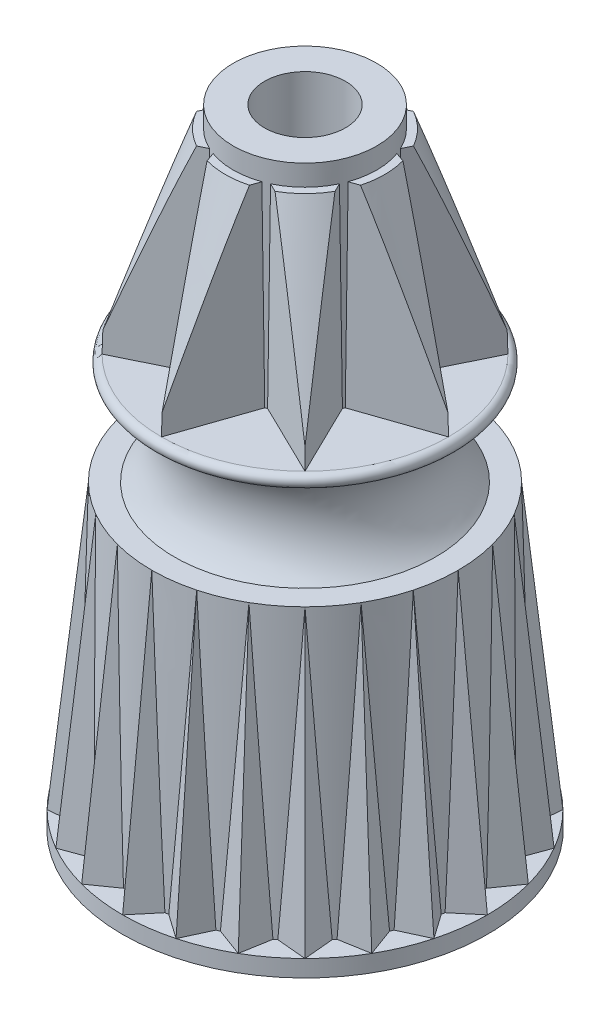
from build123d import *
from build123d.topology import SkipClean

# Parameters (mm, degrees)
SKETCH1_R           = 8.89
BOSS_EXTRUDE1_DEPTH = 0.8128
BOSS_EXTRUDE1_TAPER = 1
SKETCH2_R           = 7.4549
SKETCH3_R           = 7.8105
CIRPATTERN1_COUNT   = 24
SKETCH8_R           = 3.4925
BOSS_EXTRUDE2_DEPTH = 10.5156
SKETCH9_R           = 1.9685
CUT_EXTRUDE1_DEPTH  = 31.5308001
BOSS_EXTRUDE3_DEPTH = 9.4996
BOSS_EXTRUDE3_TAPER = 0.5
CIRPATTERN2_COUNT   = 8
FILLET1_R           = 0.762
RIB1_REACH          = 30.753
SKETCH13_WALLS_W    = 1.016
SKETCH13_WALLS_H    = 63.549878555
RIB1_DRAFT_ANGLE    = 1
FILLET2_R           = 0.508


with BuildPart() as part:
    # Sketch1 → Boss-Extrude1 (new body)
    with BuildSketch(Plane(origin=(0, 0, 0), x_dir=(1, 0, 0), z_dir=(0, 1, 0))):
        Circle(SKETCH1_R)
    extrude(amount=BOSS_EXTRUDE1_DEPTH, taper=BOSS_EXTRUDE1_TAPER)

    # Sketch2 → Loft1 section 0
    with BuildSketch(Plane(origin=(0, 14.6304, 0), x_dir=(1, 0, 0), z_dir=(0, 1, 0))):
        Circle(SKETCH2_R)
    # Sketch3 → Loft1 section 1
    with BuildSketch(Plane(origin=(0, 0.8128, 0), x_dir=(1, 0, 0), z_dir=(0, 1, 0))):
        Circle(SKETCH3_R)
    loft()

    # Sweep1: sweep along a path in Sketch4
    with SkipClean():  # keep this step's faces unmerged: merging them makes the solid invalid here
        with BuildLine(Plane(origin=(0, 0, 0), x_dir=(0, 0, -1), z_dir=(1, 0, 0))) as sweep1_path:
            Line((-8.875812523, 0.8128), (-7.4549, 14.6304))
        # Sketch5 → Sweep1 (sweep)
        with BuildSketch(Plane(origin=(0, 0.8128, 8.875812523), x_dir=(1, 0, 0), z_dir=(0, 0.994754201, -0.102294082))):
            Polygon((0, 0), (1.278787838, 1.524), (-1.278787838, 1.524), align=None)
        sweep1 = sweep(path=sweep1_path.line)

    # CirPattern1: Sweep1 ×24 about axis
    cirpattern1_axis = Axis((0, 0, 0), (0, 1, 0))
    for i in range(1, CIRPATTERN1_COUNT):
        add(sweep1.rotate(cirpattern1_axis, i * 360 / CIRPATTERN1_COUNT))

    # Sketch7 → Revolve1 (revolve)
    with BuildSketch(Plane(origin=(0, 0, 0), x_dir=(0, 0, -1), z_dir=(1, 0, 0))):
        with BuildLine():
            Line((0, 20.0152), (6.985, 20.0152))
            ThreePointArc((6.985, 20.0152), (7.3025, 19.6977), (6.985, 19.3802))
            Line((6.985, 19.3802), (6.35, 19.3802))
            ThreePointArc((6.35, 19.3802), (5.3467, 17.0053), (6.35, 14.6304))
            Line((6.35, 14.6304), (0, 14.6304))
            Line((0, 14.6304), (0, 20.0152))
        make_face()
    revolve(axis=Axis((0, 14.6304, 0), (0, 1, 0)))

    # Sketch8 → Boss-Extrude2 (add)
    with BuildSketch(Plane(origin=(0, 20.0152, 0), x_dir=(1, 0, 0), z_dir=(0, 1, 0))):
        with Locations(Location((0, 0, 0), (0, 0, 270))):  # turned: the seam where the file's is
            Circle(SKETCH8_R)
    extrude(amount=BOSS_EXTRUDE2_DEPTH)

    # Sketch9 → Cut-Extrude1 (cut, through all)
    with BuildSketch(Plane(origin=(0, 30.5308, 0), x_dir=(1, 0, 0), z_dir=(0, 1, 0))):
        with Locations(Location((0, 0, 0), (0, 0, 270))):  # turned: the seam where the file's is
            Circle(SKETCH9_R)
    extrude(amount=-CUT_EXTRUDE1_DEPTH, mode=Mode.SUBTRACT)

    # Sketch10 → Boss-Extrude3 (add)
    with BuildSketch(Plane(origin=(0, 20.0152, 0), x_dir=(1, 0, 0), z_dir=(0, 1, 0))):
        Polygon((0, -6.985), (1.56635116, -2.435985924), (-1.56635116, -2.435985924), align=None)
    boss_extrude3 = extrude(amount=BOSS_EXTRUDE3_DEPTH, taper=BOSS_EXTRUDE3_TAPER)

    # CirPattern2: Boss-Extrude3 ×8 about axis
    cirpattern2_axis = Axis((0, 0, 0), (0, 1, 0))
    for i in range(1, CIRPATTERN2_COUNT):
        add(boss_extrude3.rotate(cirpattern2_axis, i * 360 / CIRPATTERN2_COUNT))

    # Sketch11 → Cut-Revolve1 (revolve, cut)
    with BuildSketch(Plane(origin=(0, 0, 0), x_dir=(0, 0, -1), z_dir=(1, 0, 0)), mode=Mode.PRIVATE) as cut_revolve1_sk:
        Polygon((6.957775857, 21.030835193), (7.465775857, 21.030835193), (7.465775857, 30.5308), (3.4925, 30.5308), (3.4925, 29.5148), (3.8735, 29.5148), align=None)
    revolve(cut_revolve1_sk.sketch.rotate(Axis((0, 70.939881733, 0), (0, -1, 0)), 19.858501922), axis=Axis((0, 70.939881733, 0), (0, -1, 0)), mode=Mode.SUBTRACT)  # turned: the seam where the file's is

    # Sketch12 → Cut-Revolve2 (revolve, cut)
    with BuildSketch(Plane(origin=(0, 0, 0), x_dir=(0, 0, -1), z_dir=(1, 0, 0))):
        with BuildLine():
            Line((2.921, 0), (3.194108928, 15.6464))
            Line((3.194108928, 15.6464), (4.549542973, 15.6464))
            ThreePointArc((4.549542973, 15.6464), (4.990447661, 14.708323353), (5.641733851, 13.901966707))
            Line((5.641733851, 13.901966707), (5.889715871, 13.901966707))
            Line((5.889715871, 13.901966707), (6.270518716, 2.9972))
            Line((6.270518716, 2.9972), (6.448427093, 2.9972))
            Line((6.448427093, 2.9972), (6.491002495, 1.778))
            Line((6.491002495, 1.778), (6.668910872, 1.778))
            Line((6.668910872, 1.778), (6.731, 0))
            Line((6.731, 0), (6.731, -2.54))
            Line((6.731, -2.54), (2.921, -2.54))
            Line((2.921, -2.54), (2.921, 0))
        make_face()
    revolve(axis=Axis((0, 0, 0), (0, 1, 0)), mode=Mode.SUBTRACT)

    # Fillet1
    fillet1_edges = [part.edges().sort_by_distance(p)[0] for p in [
        (0, 0, 6.731),
    ]]
    fillet(fillet1_edges, radius=FILLET1_R)

    # Sketch13 walls → Rib1 (add, up to next)
    with BuildSketch(Plane.XZ.offset(-1.778), mode=Mode.PRIVATE) as rib1_sk1:
        with Locations((0, -4.468863318)):
            Rectangle(SKETCH13_WALLS_W, SKETCH13_WALLS_H)
    rib1_tool1 = extrude(rib1_sk1.sketch, amount=-RIB1_REACH, mode=Mode.PRIVATE) - part.part
    add(rib1_tool1.solids().sort_by_distance((0, 1.778, -4.468863317))[0])
    # Sketch13 walls → Rib1 (add, up to next)
    with BuildSketch(Plane.XZ.offset(-1.778), mode=Mode.PRIVATE) as rib1_sk2:
        with Locations((0, 4.468863318)):
            Rectangle(SKETCH13_WALLS_W, SKETCH13_WALLS_H)
    rib1_tool2 = extrude(rib1_sk2.sketch, amount=-RIB1_REACH, mode=Mode.PRIVATE) - part.part
    add(rib1_tool2.solids().sort_by_distance((0, 1.778, 4.468863317))[0])

    # Rib1 draft
    rib1_draft_faces = [part.faces().sort_by_distance(p)[0] for p in [
        (0.508, 2.032, -4.468863318),
        (-0.508, 2.032, -4.468863318),
        (0.508, 2.032, 4.468863318),
        (-0.508, 2.032, 4.468863318),
    ]]
    draft(rib1_draft_faces, Plane(origin=(0, 1.778, -4.468863317), x_dir=(1, 0, 0), z_dir=(0, -1, 0)), RIB1_DRAFT_ANGLE)

    # Fillet2
    fillet2_edges = [part.edges().sort_by_distance(p)[0] for p in [
        (0.508, 1.778, 4.689545246),
        (-0.508, 1.778, 4.689545246),
        (-0.508, 1.778, -4.689545246),
        (0.508, 1.778, -4.689545246),
    ]]
    fillet(fillet2_edges, radius=FILLET2_R)


solid = part.part
